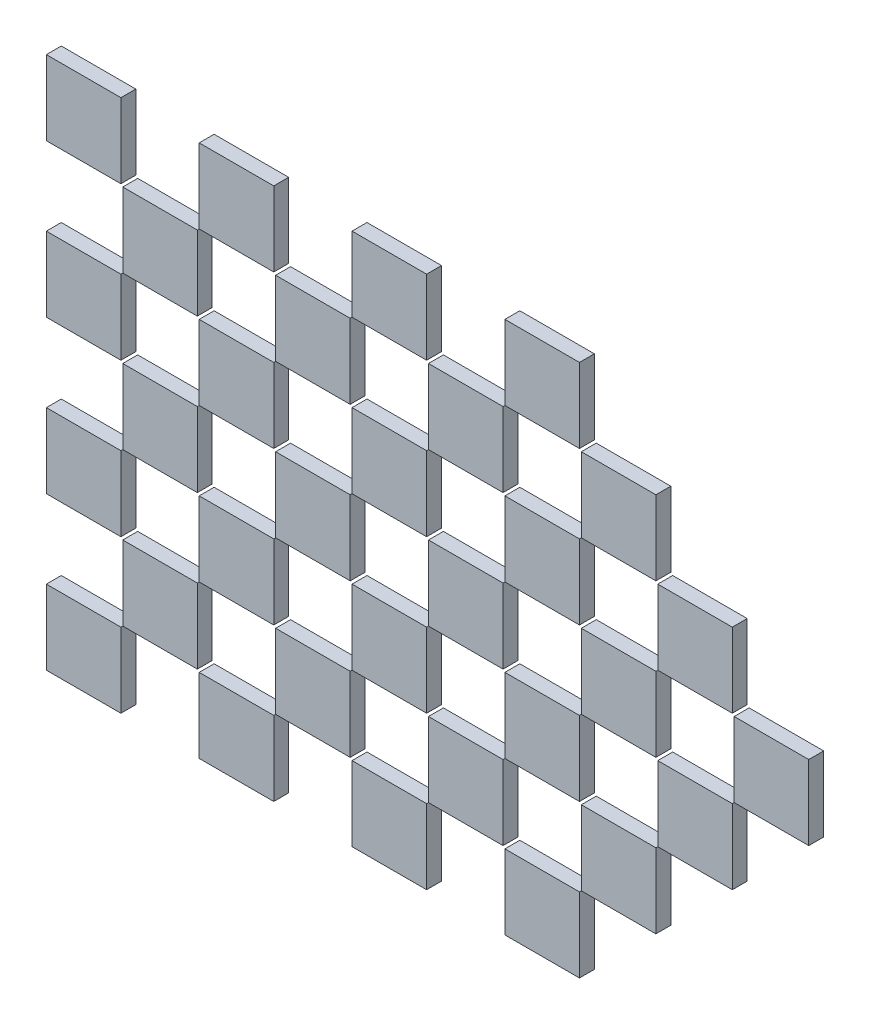
from build123d import *

# Parameters (mm, degrees)
SKETCH_1_W                  = 2
SKETCH_1_H                  = 2
EXTRUDE_1_DEPTH             = 0.4
PATTERN_LINEAR_1_COUNT      = 4
PATTERN_LINEAR_1_PITCH      = 4.1
PATTERN_LINEAR_1_2_COUNT    = 6
PATTERN_LINEAR_1_2_PITCH    = 4.1
SKETCH_2_W                  = 2
SKETCH_2_H                  = 2
EXTRUDE_2_DEPTH             = 0.4
PATTERN_LINEAR_2_COUNT      = 3
PATTERN_LINEAR_2_PITCH      = 4.1
PATTERN_LINEAR_2_COUNT_DIR2 = 5
PATTERN_LINEAR_2_PITCH_DIR2 = 4.1


with BuildPart() as part:
    # 草图1 → 凸台-拉伸1 (new body)
    with BuildSketch(Plane.XY):
        with Locations((-5.705263158, 7.115789474)):
            Rectangle(SKETCH_1_W, SKETCH_1_H)
    extrude(amount=EXTRUDE_1_DEPTH)


with BuildPart() as pattern_linear_1_1:
    # 阵列(线性)1: pattern copy
    add(part.part.moved(Location(Vector(0, 1, 0) * (1 * PATTERN_LINEAR_1_PITCH))))


with BuildPart() as pattern_linear_1_2:
    # 阵列(线性)1: pattern copy
    add(part.part.moved(Location(Vector(0, 1, 0) * (2 * PATTERN_LINEAR_1_PITCH))))


with BuildPart() as pattern_linear_1_3:
    # 阵列(线性)1: pattern copy
    add(part.part.moved(Location(Vector(0, 1, 0) * (3 * PATTERN_LINEAR_1_PITCH))))


with BuildPart() as pattern_linear_1_2_1:
    # Pattern Linear 1 2: pattern copy
    add(part.part.moved(Location(Vector(1, 0, 0) * (1 * PATTERN_LINEAR_1_2_PITCH))))


with BuildPart() as pattern_linear_1_2_2:
    # Pattern Linear 1 2: pattern copy
    add(part.part.moved(Location(Vector(1, 0, 0) * (2 * PATTERN_LINEAR_1_2_PITCH))))


with BuildPart() as pattern_linear_1_2_3:
    # Pattern Linear 1 2: pattern copy
    add(part.part.moved(Location(Vector(1, 0, 0) * (3 * PATTERN_LINEAR_1_2_PITCH))))


with BuildPart() as pattern_linear_1_2_4:
    # Pattern Linear 1 2: pattern copy
    add(part.part.moved(Location(Vector(1, 0, 0) * (4 * PATTERN_LINEAR_1_2_PITCH))))


with BuildPart() as pattern_linear_1_2_5:
    # Pattern Linear 1 2: pattern copy
    add(part.part.moved(Location(Vector(1, 0, 0) * (5 * PATTERN_LINEAR_1_2_PITCH))))


with BuildPart() as pattern_linear_1_2_6:
    # Pattern Linear 1 2: pattern copy
    add(pattern_linear_1_1.part.moved(Location(Vector(1, 0, 0) * (1 * PATTERN_LINEAR_1_2_PITCH))))


with BuildPart() as pattern_linear_1_2_7:
    # Pattern Linear 1 2: pattern copy
    add(pattern_linear_1_1.part.moved(Location(Vector(1, 0, 0) * (2 * PATTERN_LINEAR_1_2_PITCH))))


with BuildPart() as pattern_linear_1_2_8:
    # Pattern Linear 1 2: pattern copy
    add(pattern_linear_1_1.part.moved(Location(Vector(1, 0, 0) * (3 * PATTERN_LINEAR_1_2_PITCH))))


with BuildPart() as pattern_linear_1_2_9:
    # Pattern Linear 1 2: pattern copy
    add(pattern_linear_1_1.part.moved(Location(Vector(1, 0, 0) * (4 * PATTERN_LINEAR_1_2_PITCH))))


with BuildPart() as pattern_linear_1_2_10:
    # Pattern Linear 1 2: pattern copy
    add(pattern_linear_1_1.part.moved(Location(Vector(1, 0, 0) * (5 * PATTERN_LINEAR_1_2_PITCH))))


with BuildPart() as pattern_linear_1_2_11:
    # Pattern Linear 1 2: pattern copy
    add(pattern_linear_1_2.part.moved(Location(Vector(1, 0, 0) * (1 * PATTERN_LINEAR_1_2_PITCH))))


with BuildPart() as pattern_linear_1_2_12:
    # Pattern Linear 1 2: pattern copy
    add(pattern_linear_1_2.part.moved(Location(Vector(1, 0, 0) * (2 * PATTERN_LINEAR_1_2_PITCH))))


with BuildPart() as pattern_linear_1_2_13:
    # Pattern Linear 1 2: pattern copy
    add(pattern_linear_1_2.part.moved(Location(Vector(1, 0, 0) * (3 * PATTERN_LINEAR_1_2_PITCH))))


with BuildPart() as pattern_linear_1_2_14:
    # Pattern Linear 1 2: pattern copy
    add(pattern_linear_1_2.part.moved(Location(Vector(1, 0, 0) * (4 * PATTERN_LINEAR_1_2_PITCH))))


with BuildPart() as pattern_linear_1_2_15:
    # Pattern Linear 1 2: pattern copy
    add(pattern_linear_1_2.part.moved(Location(Vector(1, 0, 0) * (5 * PATTERN_LINEAR_1_2_PITCH))))


with BuildPart() as pattern_linear_1_2_16:
    # Pattern Linear 1 2: pattern copy
    add(pattern_linear_1_3.part.moved(Location(Vector(1, 0, 0) * (1 * PATTERN_LINEAR_1_2_PITCH))))


with BuildPart() as pattern_linear_1_2_17:
    # Pattern Linear 1 2: pattern copy
    add(pattern_linear_1_3.part.moved(Location(Vector(1, 0, 0) * (2 * PATTERN_LINEAR_1_2_PITCH))))


with BuildPart() as pattern_linear_1_2_18:
    # Pattern Linear 1 2: pattern copy
    add(pattern_linear_1_3.part.moved(Location(Vector(1, 0, 0) * (3 * PATTERN_LINEAR_1_2_PITCH))))


with BuildPart() as pattern_linear_1_2_19:
    # Pattern Linear 1 2: pattern copy
    add(pattern_linear_1_3.part.moved(Location(Vector(1, 0, 0) * (4 * PATTERN_LINEAR_1_2_PITCH))))


with BuildPart() as pattern_linear_1_2_20:
    # Pattern Linear 1 2: pattern copy
    add(pattern_linear_1_3.part.moved(Location(Vector(1, 0, 0) * (5 * PATTERN_LINEAR_1_2_PITCH))))


with BuildPart() as body_25:
    # 草图2 → 凸台-拉伸2 (new body)
    with BuildSketch(Plane.XY):
        with Locations((-3.655263158, 9.165789474)):
            Rectangle(SKETCH_2_W, SKETCH_2_H)
    extrude_2 = extrude(amount=EXTRUDE_2_DEPTH)


with BuildPart() as pattern_linear_2_1:
    # 阵列(线性)2: pattern copy
    add(extrude_2.moved(Location(Vector(0, 1, 0) * (0 * PATTERN_LINEAR_2_PITCH) + Vector(1, 0, 0) * (1 * PATTERN_LINEAR_2_PITCH_DIR2))))


with BuildPart() as pattern_linear_2_2:
    # 阵列(线性)2: pattern copy
    add(extrude_2.moved(Location(Vector(0, 1, 0) * (0 * PATTERN_LINEAR_2_PITCH) + Vector(1, 0, 0) * (2 * PATTERN_LINEAR_2_PITCH_DIR2))))


with BuildPart() as pattern_linear_2_3:
    # 阵列(线性)2: pattern copy
    add(extrude_2.moved(Location(Vector(0, 1, 0) * (0 * PATTERN_LINEAR_2_PITCH) + Vector(1, 0, 0) * (3 * PATTERN_LINEAR_2_PITCH_DIR2))))


with BuildPart() as pattern_linear_2_4:
    # 阵列(线性)2: pattern copy
    add(extrude_2.moved(Location(Vector(0, 1, 0) * (0 * PATTERN_LINEAR_2_PITCH) + Vector(1, 0, 0) * (4 * PATTERN_LINEAR_2_PITCH_DIR2))))


with BuildPart() as pattern_linear_2_5:
    # 阵列(线性)2: pattern copy
    add(extrude_2.moved(Location(Vector(0, 1, 0) * (1 * PATTERN_LINEAR_2_PITCH) + Vector(1, 0, 0) * (0 * PATTERN_LINEAR_2_PITCH_DIR2))))


with BuildPart() as pattern_linear_2_6:
    # 阵列(线性)2: pattern copy
    add(extrude_2.moved(Location(Vector(0, 1, 0) * (1 * PATTERN_LINEAR_2_PITCH) + Vector(1, 0, 0) * (1 * PATTERN_LINEAR_2_PITCH_DIR2))))


with BuildPart() as pattern_linear_2_7:
    # 阵列(线性)2: pattern copy
    add(extrude_2.moved(Location(Vector(0, 1, 0) * (1 * PATTERN_LINEAR_2_PITCH) + Vector(1, 0, 0) * (2 * PATTERN_LINEAR_2_PITCH_DIR2))))


with BuildPart() as pattern_linear_2_8:
    # 阵列(线性)2: pattern copy
    add(extrude_2.moved(Location(Vector(0, 1, 0) * (1 * PATTERN_LINEAR_2_PITCH) + Vector(1, 0, 0) * (3 * PATTERN_LINEAR_2_PITCH_DIR2))))


with BuildPart() as pattern_linear_2_9:
    # 阵列(线性)2: pattern copy
    add(extrude_2.moved(Location(Vector(0, 1, 0) * (1 * PATTERN_LINEAR_2_PITCH) + Vector(1, 0, 0) * (4 * PATTERN_LINEAR_2_PITCH_DIR2))))


with BuildPart() as pattern_linear_2_10:
    # 阵列(线性)2: pattern copy
    add(extrude_2.moved(Location(Vector(0, 1, 0) * (2 * PATTERN_LINEAR_2_PITCH) + Vector(1, 0, 0) * (0 * PATTERN_LINEAR_2_PITCH_DIR2))))


with BuildPart() as pattern_linear_2_11:
    # 阵列(线性)2: pattern copy
    add(extrude_2.moved(Location(Vector(0, 1, 0) * (2 * PATTERN_LINEAR_2_PITCH) + Vector(1, 0, 0) * (1 * PATTERN_LINEAR_2_PITCH_DIR2))))


with BuildPart() as pattern_linear_2_12:
    # 阵列(线性)2: pattern copy
    add(extrude_2.moved(Location(Vector(0, 1, 0) * (2 * PATTERN_LINEAR_2_PITCH) + Vector(1, 0, 0) * (2 * PATTERN_LINEAR_2_PITCH_DIR2))))


with BuildPart() as pattern_linear_2_13:
    # 阵列(线性)2: pattern copy
    add(extrude_2.moved(Location(Vector(0, 1, 0) * (2 * PATTERN_LINEAR_2_PITCH) + Vector(1, 0, 0) * (3 * PATTERN_LINEAR_2_PITCH_DIR2))))


with BuildPart() as pattern_linear_2_14:
    # 阵列(线性)2: pattern copy
    add(extrude_2.moved(Location(Vector(0, 1, 0) * (2 * PATTERN_LINEAR_2_PITCH) + Vector(1, 0, 0) * (4 * PATTERN_LINEAR_2_PITCH_DIR2))))


solid = Compound([part.part, pattern_linear_1_1.part, pattern_linear_1_2.part, pattern_linear_1_3.part, pattern_linear_1_2_1.part, pattern_linear_1_2_2.part, pattern_linear_1_2_3.part, pattern_linear_1_2_6.part, pattern_linear_1_2_7.part, pattern_linear_1_2_8.part, pattern_linear_1_2_9.part, pattern_linear_1_2_11.part, pattern_linear_1_2_12.part, pattern_linear_1_2_13.part, pattern_linear_1_2_14.part, pattern_linear_1_2_16.part, pattern_linear_1_2_17.part, pattern_linear_1_2_18.part, body_25.part, pattern_linear_2_1.part, pattern_linear_2_2.part, pattern_linear_2_3.part, pattern_linear_2_5.part, pattern_linear_2_6.part, pattern_linear_2_7.part, pattern_linear_2_8.part, pattern_linear_2_9.part, pattern_linear_2_10.part, pattern_linear_2_11.part, pattern_linear_2_12.part, pattern_linear_2_13.part])
